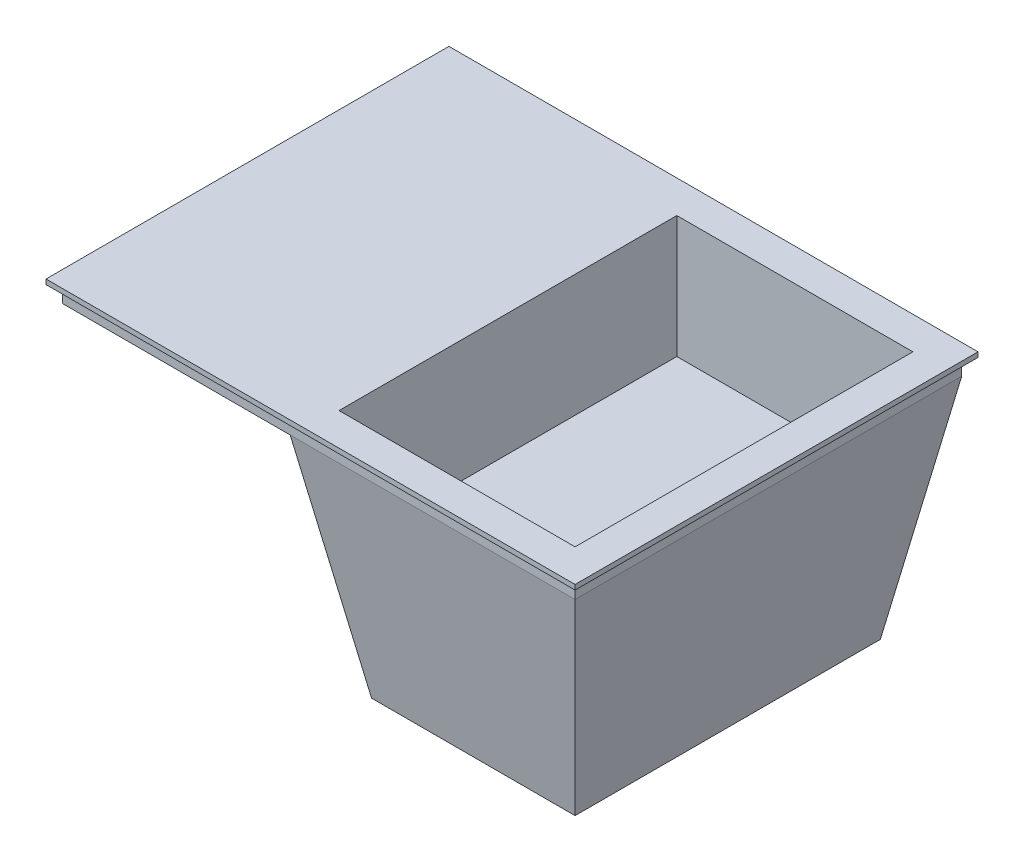
from build123d import *

# Parameters (mm, degrees)
SKETCH_1_W               = 630
SKETCH_1_H               = 475
EXTRUDE_1_DEPTH          = 300
CUT_EXTRUDE_1_DEPTH      = 1
CUT_EXTRUDE_1_DEPTH_BACK = 476
SKETCH_3_W               = 650
SKETCH_3_H               = 495
EXTRUDE_2_DEPTH          = 6
CUT_EXTRUDE_2_DEPTH      = 11
CUT_EXTRUDE_2_DEPTH_BACK = 641
SKETCH_5_W               = 290
SKETCH_5_H               = 415
CUT_EXTRUDE_4_DEPTH      = 150


with BuildPart() as part:
    # Эскиз1 → Бобышка-Вытянуть1 (new body)
    with BuildSketch(Plane(origin=(0, 0, 0), x_dir=(1, 0, 0), z_dir=(0, 1, 0))):
        Rectangle(SKETCH_1_W, SKETCH_1_H)
    extrude(amount=EXTRUDE_1_DEPTH)

    # Эскиз2 → Вырез-Вытянуть1 (cut, two sides)
    with BuildSketch(Plane.XY.offset(237.5)) as cut_extrude_1_sk:
        Polygon((-315, 0), (15, 0), (-35, 280), (-315, 280), align=None)
        Polygon((315, 280), (265, 0), (315, 0), align=None)
    extrude(amount=CUT_EXTRUDE_1_DEPTH, mode=Mode.SUBTRACT)
    extrude(cut_extrude_1_sk.sketch, amount=-CUT_EXTRUDE_1_DEPTH_BACK, mode=Mode.SUBTRACT)

    # Эскиз3 → Бобышка-Вытянуть2 (add)
    with BuildSketch(Plane(origin=(0, 300, 0), x_dir=(1, 0, 0), z_dir=(0, 1, 0))):
        Rectangle(SKETCH_3_W, SKETCH_3_H)
    extrude(amount=EXTRUDE_2_DEPTH)

    # Эскиз4 → Вырез-Вытянуть2 (cut, two sides)
    with BuildSketch(Plane(origin=(315, 0, 0), x_dir=(0, 0, -1), z_dir=(1, 0, 0))) as cut_extrude_2_sk:
        Polygon((-237.5, 280), (-187.5, 0), (-237.5, 0), align=None)
        Polygon((237.5, 280), (237.5, 0), (187.5, 0), align=None)
    extrude(amount=CUT_EXTRUDE_2_DEPTH, mode=Mode.SUBTRACT)
    extrude(cut_extrude_2_sk.sketch, amount=-CUT_EXTRUDE_2_DEPTH_BACK, mode=Mode.SUBTRACT)

    # Эскиз5 → Вырез-Вытянуть4 (cut)
    with BuildSketch(Plane(origin=(0, 306, 0), x_dir=(1, 0, 0), z_dir=(0, 1, 0))):
        with Locations((140, 0)):
            Rectangle(SKETCH_5_W, SKETCH_5_H)
    extrude(amount=-CUT_EXTRUDE_4_DEPTH, mode=Mode.SUBTRACT)


solid = part.part
